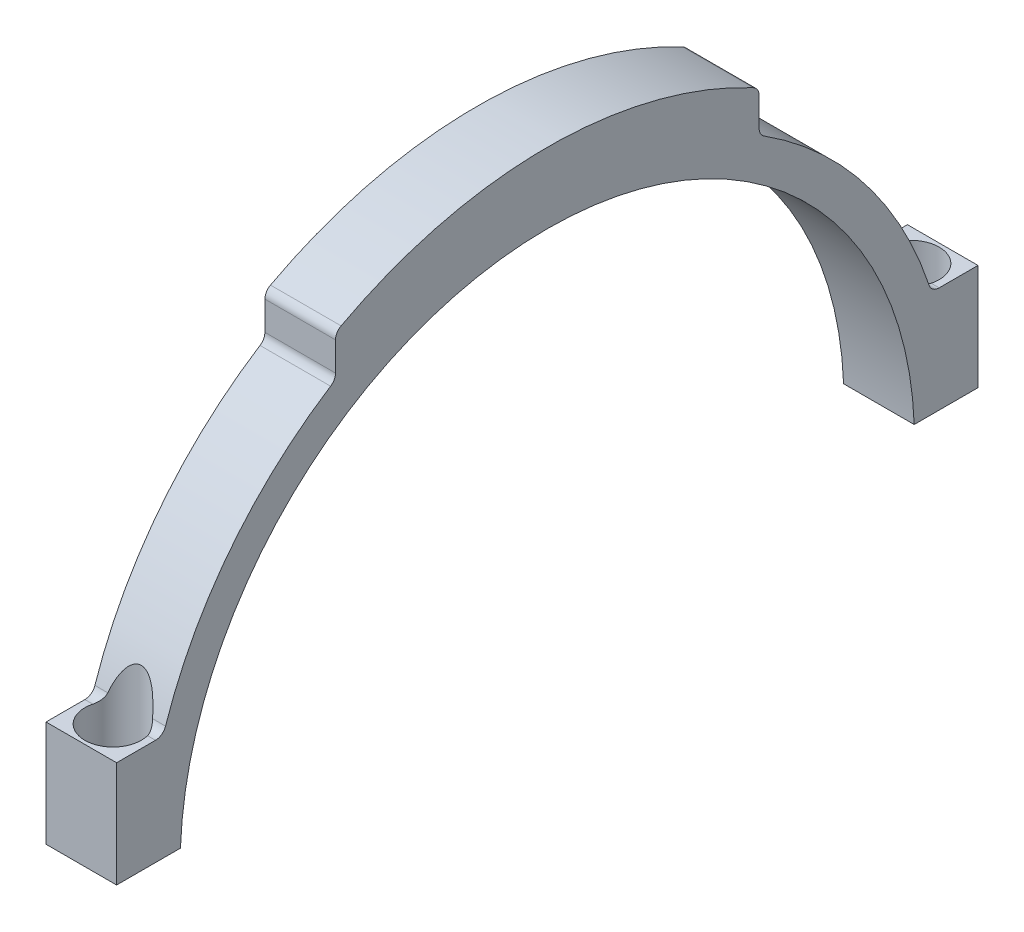
from build123d import *

# Parameters (mm, degrees)
BOSS_EXTRUDE1_DEPTH        = 10
M4_TAPPED_HOLE1_AT_2_COUNT = 2
M4_TAPPED_HOLE1_AT_2_PITCH = 113
SKETCH7_R                  = 4
CUT_EXTRUDE1_DEPTH         = 10
CUT_EXTRUDE1_DEPTH_BACK    = 6.6


with BuildPart() as part:
    # Sketch1 → Boss-Extrude1 (new body)
    with BuildSketch(Plane(origin=(0, 0, 0), x_dir=(0, 0, -1), z_dir=(1, 0, 0))):
        with BuildLine():
            Line((-30, 53.366656257), (-30, 49.295030175))
            ThreePointArc((-30, 49.295030175), (-30.184412971, 48.574453483), (-30.692307692, 48.031055043))
            ThreePointArc((-30.692307692, 48.031055043), (-44.960469582, 35.036497755), (-54.07472853, 18.025641026))
            ThreePointArc((-54.07472853, 18.025641026), (-54.620689683, 17.283131383), (-55.497747702, 17))
            Line((-55.497747702, 17), (-61.001524227, 17))
            Line((-61.001524227, 17), (-61.001524227, 2))
            Line((-61.001524227, 2), (-51.961524227, 2))
            ThreePointArc((-51.961524227, 2), (0, 52), (51.961524227, 2))
            Line((51.961524227, 2), (60.998475773, 2))
            Line((60.998475773, 2), (60.998475773, 17))
            Line((60.998475773, 17), (55.497747702, 17))
            ThreePointArc((55.497747702, 17), (54.620689683, 17.283131383), (54.07472853, 18.025641026))
            ThreePointArc((54.07472853, 18.025641026), (44.960469582, 35.036497755), (30.692307692, 48.031055043))
            ThreePointArc((30.692307692, 48.031055043), (30.184412971, 48.574453483), (30, 49.295030175))
            Line((30, 49.295030175), (30, 53.366656257))
            ThreePointArc((30, 53.366656257), (29.786451973, 54.138045472), (29.20661157, 54.689796494))
            ThreePointArc((29.20661157, 54.689796494), (0, 62), (-29.20661157, 54.689796494))
            ThreePointArc((-29.20661157, 54.689796494), (-29.786451973, 54.138045472), (-30, 53.366656257))
        make_face()
    extrude(amount=BOSS_EXTRUDE1_DEPTH)

    # Sketch4 → M4 Tapped Hole1 (revolve, cut)
    with BuildSketch(Plane(origin=(5, 17, -56.498475773), x_dir=(0, 0, 1), z_dir=(1, 0, 0))):
        Polygon((0, 0), (0, 21.091420021), (1.65, 20.1), (1.65, 0), align=None)
    m4_tapped_hole1 = revolve(axis=Axis((5, 23.35, -56.498475773), (0, -1, 0)), mode=Mode.SUBTRACT)

    # M4 Tapped Hole1 at 2: M4 Tapped Hole1 ×2
    with Locations(*[(0, 0, i * M4_TAPPED_HOLE1_AT_2_PITCH) for i in range(1, M4_TAPPED_HOLE1_AT_2_COUNT)]):
        add(m4_tapped_hole1, mode=Mode.SUBTRACT)

    # Sketch7 → Cut-Extrude1 (cut, two sides)
    with BuildSketch(Plane(origin=(0, 17, 0), x_dir=(1, 0, 0), z_dir=(0, 1, 0))) as cut_extrude1_sk:
        with Locations((5, 56.498475773)):
            Circle(SKETCH7_R)
        with Locations((5, -56.501524227)):
            Circle(SKETCH7_R)
    extrude(amount=CUT_EXTRUDE1_DEPTH, mode=Mode.SUBTRACT)
    extrude(cut_extrude1_sk.sketch, amount=-CUT_EXTRUDE1_DEPTH_BACK, mode=Mode.SUBTRACT)


solid = part.part
